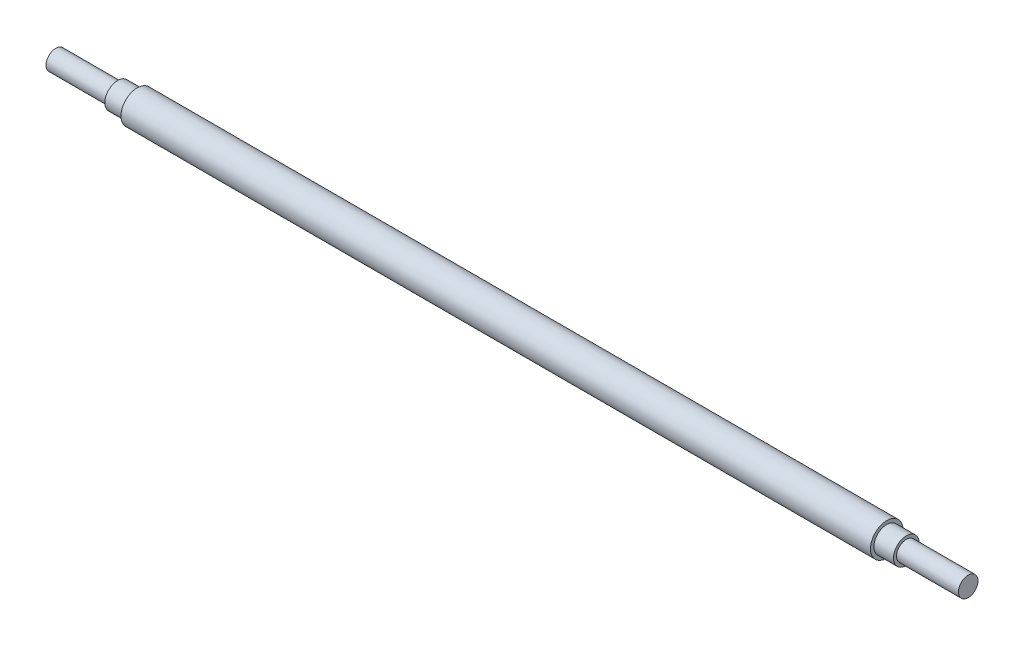
from build123d import *


with BuildPart() as part:
    # 草图1 → 旋转1 (revolve)
    with BuildSketch(Plane.XY):
        Polygon((-27.362637363, 0), (252.637362637, 0), (252.637362637, 3), (233.637362637, 3), (233.637362637, 3.95), (227.637362637, 3.95), (227.637362637, 5), (-2.362637363, 5), (-2.362637363, 3.95), (-8.362637363, 3.95), (-8.362637363, 3), (-27.362637363, 3), align=None)
    revolve(axis=Axis((-47.912087912, 0, 0), (1, 0, 0)))


solid = part.part
